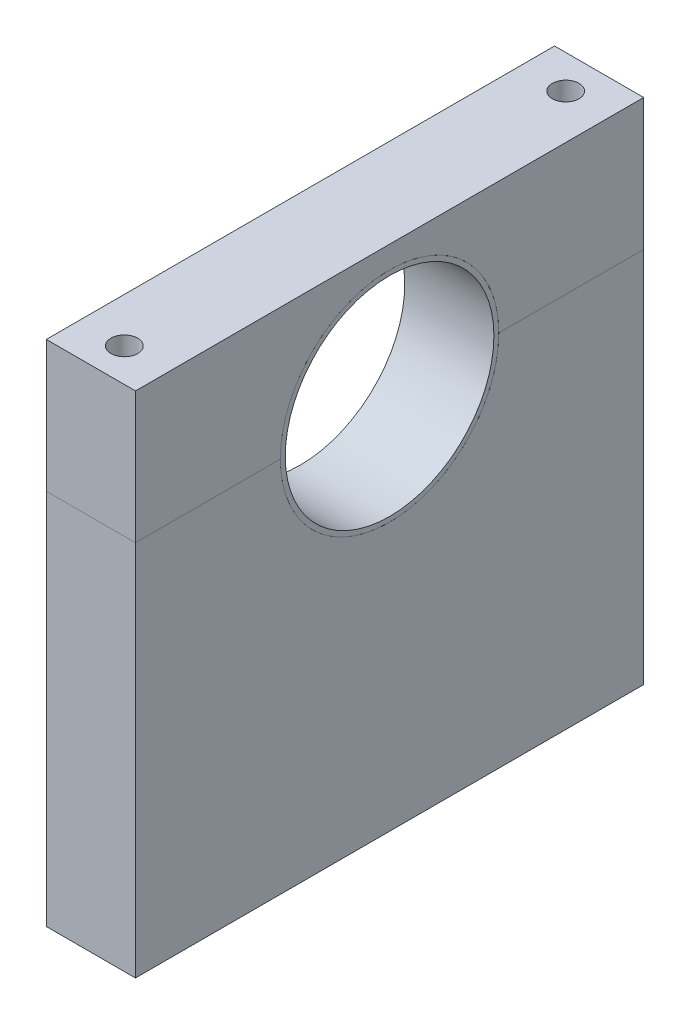
from build123d import *

# Parameters (mm, degrees)
BOSS_EXTRUDE2_DEPTH = 20
BOSS_EXTRUDE3_DEPTH = 20
SKETCH3_R           = 3
CUT_EXTRUDE1_DEPTH  = 59
SKETCH4_W           = 20
SKETCH4_H           = 114
SKETCH4_R           = 3
BOSS_EXTRUDE5_DEPTH = 55.05
SKETCH5_R           = 23.4
CUT_EXTRUDE2_DEPTH  = 34


with BuildPart() as part:
    # Sketch1 → Revolve1 (revolve)
    with BuildSketch(Plane.XY):
        Polygon((-44.079026729, 28.048179476), (-34.079026729, 28.048179476), (-34.079026729, 25.048179476), (-29.079026729, 25.048179476), (-29.079026729, 35.048179476), (-49.079026729, 35.048179476), (-49.079026729, 28.048179476), (-46.079026729, 28.048179476), (-46.079026729, 29.048179476), (-44.079026729, 29.048179476), align=None)
    revolve(axis=Axis((-85.067898311, 10.548179476, 0), (1, 0, 0)))

    # Sketch5 → Cut-Extrude2 (cut)
    with BuildSketch(Plane(origin=(-29.079026729, 0, 0), x_dir=(0, 0, -1), z_dir=(1, 0, 0))):
        with Locations((0, 10.548179476)):
            Circle(SKETCH5_R)
    extrude(amount=-CUT_EXTRUDE2_DEPTH, mode=Mode.SUBTRACT)


with BuildPart() as body_2:
    # Sketch2 → Boss-Extrude2 (new body)
    with BuildSketch(Plane.ZY.offset(49.079026729)):
        with BuildLine():
            Line((-57, 10.548179476), (-24.5, 10.548179476))
            ThreePointArc((-24.5, 10.548179476), (0, 35.048179476), (24.5, 10.548179476))
            Line((24.5, 10.548179476), (57, 10.548179476))
            Line((57, 10.548179476), (57, 40.048179476))
            Line((57, 40.048179476), (-57, 40.048179476))
            Line((-57, 40.048179476), (-57, 10.548179476))
        make_face()
    extrude(amount=-BOSS_EXTRUDE2_DEPTH)


with BuildPart() as body_3:
    # Sketch2_3 → Boss-Extrude3 (new body)
    with BuildSketch(Plane.ZY.offset(49.079026729)):
        with BuildLine():
            ThreePointArc((24.5, 10.548179476), (0, -13.951820524), (-24.5, 10.548179476))
            Line((-24.5, 10.548179476), (-57, 10.548179476))
            Line((-57, 10.548179476), (-57, -18.951820524))
            Line((-57, -18.951820524), (57, -18.951820524))
            Line((57, -18.951820524), (57, 10.548179476))
            Line((57, 10.548179476), (24.5, 10.548179476))
        make_face()
    extrude(amount=-BOSS_EXTRUDE3_DEPTH)


with BuildPart() as cut_extrude1_tool:
    # Sketch3 → Cut-Extrude1 (new body)
    with BuildSketch(Plane(origin=(0, 40.048179476, 0), x_dir=(1, 0, 0), z_dir=(0, 1, 0))):
        with Locations((-39.079026729, 49.5)):
            Circle(SKETCH3_R)
        with Locations((-39.079026729, -49.5)):
            Circle(SKETCH3_R)
    extrude(amount=-CUT_EXTRUDE1_DEPTH)


with BuildPart() as body_2_1:
    add(body_2.part)

    # Cut-Extrude1: cut by cut_extrude1_tool
    add(cut_extrude1_tool.part, mode=Mode.SUBTRACT)


with BuildPart() as body_3_1:
    add(body_3.part)

    # Cut-Extrude1: cut by cut_extrude1_tool
    add(cut_extrude1_tool.part, mode=Mode.SUBTRACT)

    # Sketch4 → Boss-Extrude5 (add)
    with BuildSketch(Plane.XZ.offset(18.951820524)):
        with Locations((-39.079026729, 0)):
            Rectangle(SKETCH4_W, SKETCH4_H)
        with Locations((-39.079026729, 49.5)):
            Circle(SKETCH4_R, mode=Mode.SUBTRACT)
        with Locations((-39.079026729, -49.5)):
            Circle(SKETCH4_R, mode=Mode.SUBTRACT)
    extrude(amount=BOSS_EXTRUDE5_DEPTH)


solid = Compound([part.part, body_2_1.part, body_3_1.part])
